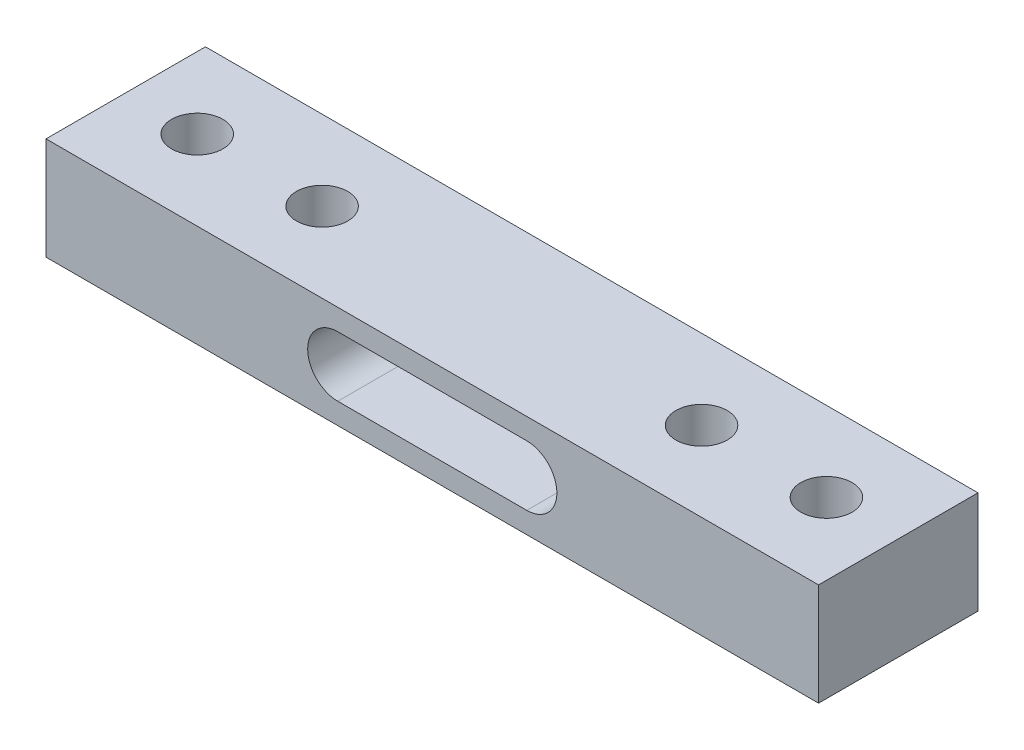
from build123d import *

# Parameters (mm, degrees)
SKETCH1_W                 = 45.16
SKETCH1_H                 = 5.99
BOSS_EXTRUDE1_DEPTH       = 9.32
F_3_0MM_DOWEL_HOLE1_D     = 3
F_3_0MM_DOWEL_HOLE1_DEPTH = 10
F_3_0MM_DOWEL_HOLE1_TIP   = 0.901290929


with BuildPart() as part:
    # Sketch1 → Boss-Extrude1 (new body)
    with BuildSketch(Plane.XY):
        Rectangle(SKETCH1_W, SKETCH1_H)
        with BuildLine():
            Line((5.523637636, -1.760435864), (-5.523637636, -1.760435864))
            ThreePointArc((-5.523637636, -1.760435864), (-7.284073501, 0), (-5.523637636, 1.760435864))
            Line((-5.523637636, 1.760435864), (5.523637636, 1.760435864))
            ThreePointArc((5.523637636, 1.760435864), (7.284073501, 0), (5.523637636, -1.760435864))
        make_face(mode=Mode.SUBTRACT)
    extrude(amount=BOSS_EXTRUDE1_DEPTH)

    # Ø3.0mm Dowel Hole1
    with Locations(Plane(origin=(0, 2.995, 0), x_dir=(1, 0, 0), z_dir=(0, 1, 0))):
        with Locations((-18.4, -4.66), (-11.1, -4.66), (11.08, -4.66), (18.38, -4.66)):
            Hole(F_3_0MM_DOWEL_HOLE1_D / 2, depth=F_3_0MM_DOWEL_HOLE1_DEPTH)
            with Locations((0, 0, -(F_3_0MM_DOWEL_HOLE1_DEPTH + F_3_0MM_DOWEL_HOLE1_TIP / 2))):  # 118° drill point
                Cone(0, F_3_0MM_DOWEL_HOLE1_D / 2, F_3_0MM_DOWEL_HOLE1_TIP, mode=Mode.SUBTRACT)


solid = part.part
